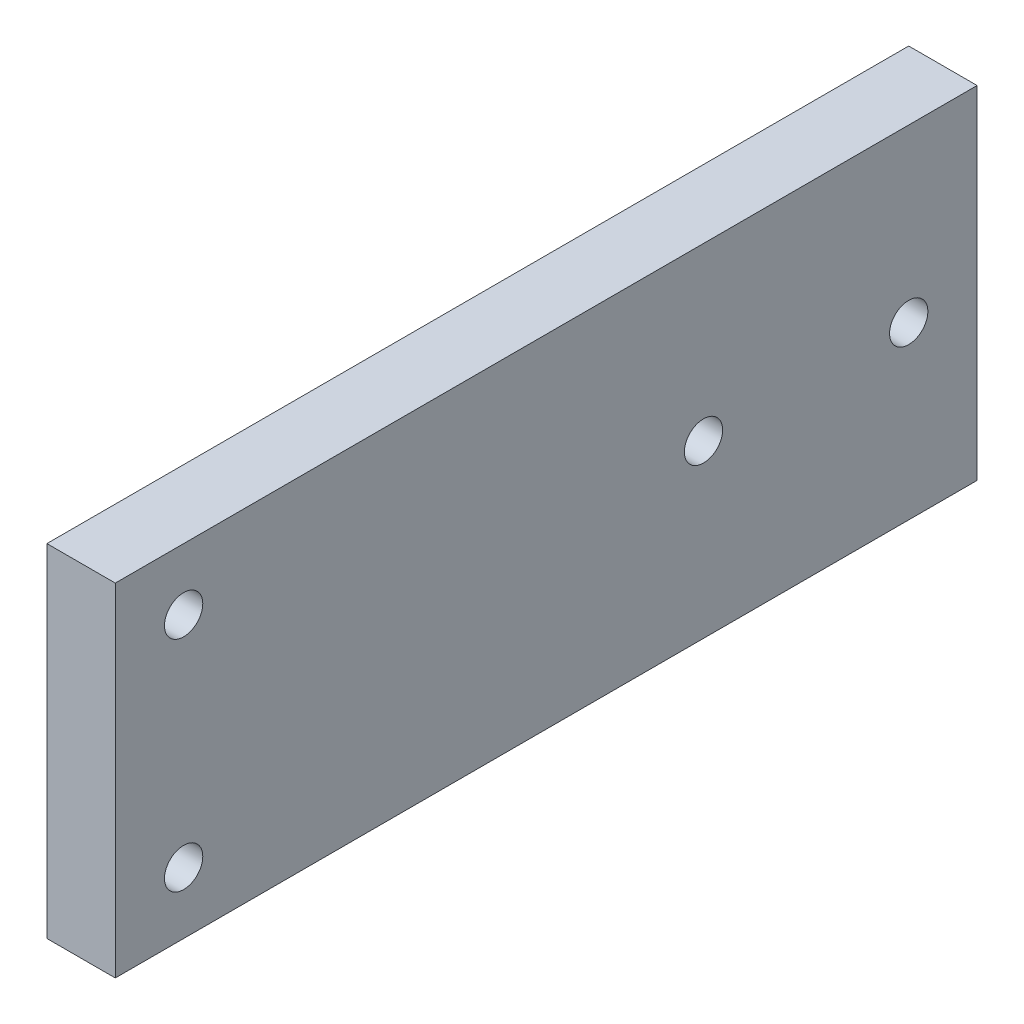
from build123d import *

# Parameters (mm, degrees)
SKETCH_1_W      = 62.995
SKETCH_1_H      = 25
SKETCH_1_R      = 1.4
EXTRUDE_1_DEPTH = 2.5


with BuildPart() as part:
    # 草图1 → 凸台-拉伸1 (new body, symmetric)
    with BuildSketch(Plane(origin=(0, 0, 0), x_dir=(0, 0, -1), z_dir=(1, 0, 0))):
        with Locations((31.4975, 12.5)):
            Rectangle(SKETCH_1_W, SKETCH_1_H)
        with Locations((4.995, 4.5)):
            Circle(SKETCH_1_R, mode=Mode.SUBTRACT)
        with Locations((4.995, 20.5)):
            Circle(SKETCH_1_R, mode=Mode.SUBTRACT)
        with Locations((42.995, 12.5)):
            Circle(SKETCH_1_R, mode=Mode.SUBTRACT)
        with Locations((57.995, 12.5)):
            Circle(SKETCH_1_R, mode=Mode.SUBTRACT)
    extrude(amount=EXTRUDE_1_DEPTH, both=True)


solid = part.part
